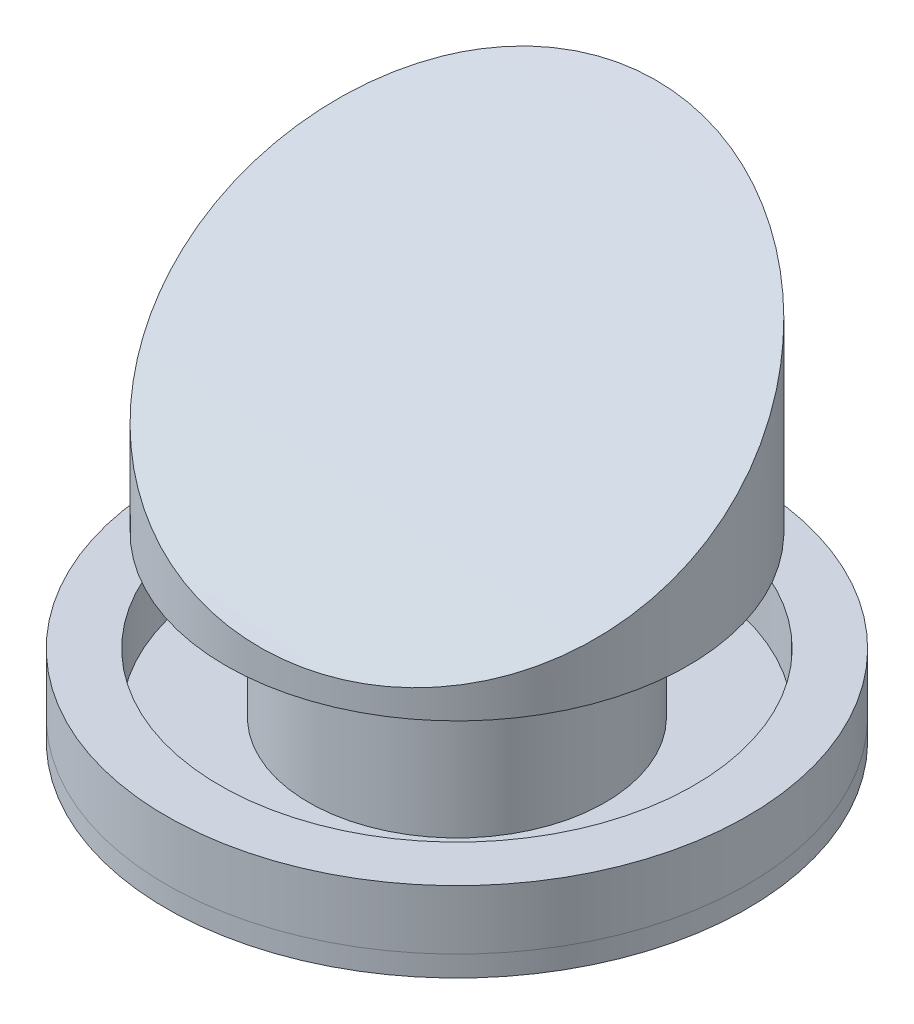
from build123d import *

# Parameters (mm, degrees)
ESBO_O4_R                            = 12
CORTE_EXTRUS_O1_DEPTH                = 776
ESBO_O3_W                            = 90
ESBO_O3_H                            = 100
FURO_ROSCADO_DE_M20X1_01_AT_2_COUNT  = 2
FURO_ROSCADO_DE_M20X1_01_AT_2_PITCH  = 140.791018536
FURO_ROSCADO_DE_M20X1_01_AT_3_COUNT  = 2
FURO_ROSCADO_DE_M20X1_01_AT_3_PITCH  = 278.115294937
FURO_ROSCADO_DE_M20X1_01_AT_4_COUNT  = 2
FURO_ROSCADO_DE_M20X1_01_AT_4_PITCH  = 408.591449766
FURO_ROSCADO_DE_M20X1_01_AT_5_COUNT  = 2
FURO_ROSCADO_DE_M20X1_01_AT_5_PITCH  = 529.006727063
FURO_ROSCADO_DE_M20X1_01_AT_6_COUNT  = 2
FURO_ROSCADO_DE_M20X1_01_AT_6_PITCH  = 636.396103068
FURO_ROSCADO_DE_M20X1_01_AT_7_COUNT  = 2
FURO_ROSCADO_DE_M20X1_01_AT_7_PITCH  = 728.115294937
FURO_ROSCADO_DE_M20X1_01_AT_8_COUNT  = 2
FURO_ROSCADO_DE_M20X1_01_AT_8_PITCH  = 801.90587177
FURO_ROSCADO_DE_M20X1_01_AT_9_COUNT  = 2
FURO_ROSCADO_DE_M20X1_01_AT_9_PITCH  = 855.950864666
FURO_ROSCADO_DE_M20X1_01_AT_10_COUNT = 2
FURO_ROSCADO_DE_M20X1_01_AT_10_PITCH = 888.919506536
FURO_ROSCADO_DE_M20X1_01_AT_11_COUNT = 2
FURO_ROSCADO_DE_M20X1_01_AT_11_PITCH = 900
FURO_ROSCADO_DE_M20X1_01_AT_12_COUNT = 2
FURO_ROSCADO_DE_M20X1_01_AT_12_PITCH = 888.919506536
FURO_ROSCADO_DE_M20X1_01_AT_13_COUNT = 2
FURO_ROSCADO_DE_M20X1_01_AT_13_PITCH = 855.950864666
FURO_ROSCADO_DE_M20X1_01_AT_14_COUNT = 2
FURO_ROSCADO_DE_M20X1_01_AT_14_PITCH = 801.90587177
FURO_ROSCADO_DE_M20X1_01_AT_15_COUNT = 2
FURO_ROSCADO_DE_M20X1_01_AT_15_PITCH = 728.115294937
FURO_ROSCADO_DE_M20X1_01_AT_16_COUNT = 2
FURO_ROSCADO_DE_M20X1_01_AT_16_PITCH = 636.396103068
FURO_ROSCADO_DE_M20X1_01_AT_17_COUNT = 2
FURO_ROSCADO_DE_M20X1_01_AT_17_PITCH = 529.006727063
FURO_ROSCADO_DE_M20X1_01_AT_18_COUNT = 2
FURO_ROSCADO_DE_M20X1_01_AT_18_PITCH = 408.591449766
FURO_ROSCADO_DE_M20X1_01_AT_19_COUNT = 2
FURO_ROSCADO_DE_M20X1_01_AT_19_PITCH = 278.115294937
FURO_ROSCADO_DE_M20X1_01_AT_20_COUNT = 2
FURO_ROSCADO_DE_M20X1_01_AT_20_PITCH = 140.791018536


with BuildPart() as part:
    # Esboço2 → Revolução1 (revolve)
    with BuildSketch(Plane.XY):
        Polygon((0, 0), (490, 0), (490, 35), (250, 35), (250, 305), (390, 305), (390, 775), (0, 775), (0, 305), (230, 305), (230, 35), (0, 35), align=None)
    revolve(axis=Axis((0, 0, 0), (0, 1, 0)))

    # Esboço4 → Corte-extrusão1 (cut, through all)
    with BuildSketch(Plane(origin=(0, 0, 0), x_dir=(-1, 0, 0), z_dir=(0, -1, 0))):
        with Locations((0, -450)):
            Circle(ESBO_O4_R)
        with Locations((-139.057647469, -427.975432333)):
            Circle(ESBO_O4_R)
        with Locations((-264.503363532, -364.057647469)):
            Circle(ESBO_O4_R)
        with Locations((-364.057647469, -264.503363532)):
            Circle(ESBO_O4_R)
        with Locations((-427.975432333, -139.057647469)):
            Circle(ESBO_O4_R)
        with Locations((-450, 0)):
            Circle(ESBO_O4_R)
        with Locations((-427.975432333, 139.057647469)):
            Circle(ESBO_O4_R)
        with Locations((-364.057647469, 264.503363532)):
            Circle(ESBO_O4_R)
        with Locations((-264.503363532, 364.057647469)):
            Circle(ESBO_O4_R)
        with Locations((-139.057647469, 427.975432333)):
            Circle(ESBO_O4_R)
        with Locations((0, 450)):
            Circle(ESBO_O4_R)
        with Locations((139.057647469, 427.975432333)):
            Circle(ESBO_O4_R)
        with Locations((264.503363532, 364.057647469)):
            Circle(ESBO_O4_R)
        with Locations((364.057647469, 264.503363532)):
            Circle(ESBO_O4_R)
        with Locations((427.975432333, 139.057647469)):
            Circle(ESBO_O4_R)
        with Locations((450, 0)):
            Circle(ESBO_O4_R)
        with Locations((427.975432333, -139.057647469)):
            Circle(ESBO_O4_R)
        with Locations((364.057647469, -264.503363532)):
            Circle(ESBO_O4_R)
        with Locations((264.503363532, -364.057647469)):
            Circle(ESBO_O4_R)
        with Locations((139.057647469, -427.975432333)):
            Circle(ESBO_O4_R)
    extrude(amount=-CORTE_EXTRUS_O1_DEPTH, mode=Mode.SUBTRACT)

    # Esboço10 → Corte-Revolução1 (revolve, cut)
    with BuildSketch(Plane.XY.offset(2200)):
        Polygon((-5755, 9250), (1345, 10524), (1345, 5159), (-5755, 5159), align=None)
    revolve(axis=Axis((1345, 5159, 2200), (-1, 0, 0)), mode=Mode.SUBTRACT)


with BuildPart() as body_2:
    # Esboço3 → Revolução2 (revolve)
    with BuildSketch(Plane.XY):
        with Locations((445, 85)):
            Rectangle(ESBO_O3_W, ESBO_O3_H)
    revolve(axis=Axis((0, 0, 0), (0, 1, 0)))

    # Esboço5 → Furo roscado de M20x1.01 (revolve, cut)
    with BuildSketch(Plane(origin=(0, 35, 450), x_dir=(0, 0, -1), z_dir=(1, 0, 0))):
        Polygon((0, 0), (0, 50.878175881), (9.5, 45.17), (9.5, 0), align=None)
    furo_roscado_de_m20x1_01 = revolve(axis=Axis((0, 28.65, 450), (0, 1, 0)), mode=Mode.SUBTRACT)

    # Furo roscado de M20x1.01 at 2: Furo roscado de M20x1.01 ×2
    with Locations(*[Vector(0.987688341, 0, -0.156434465) * (i * FURO_ROSCADO_DE_M20X1_01_AT_2_PITCH) for i in range(1, FURO_ROSCADO_DE_M20X1_01_AT_2_COUNT)]):
        add(furo_roscado_de_m20x1_01, mode=Mode.SUBTRACT)

    # Furo roscado de M20x1.01 at 3: Furo roscado de M20x1.01 ×2
    with Locations(*[Vector(0.951056516, 0, -0.309016994) * (i * FURO_ROSCADO_DE_M20X1_01_AT_3_PITCH) for i in range(1, FURO_ROSCADO_DE_M20X1_01_AT_3_COUNT)]):
        add(furo_roscado_de_m20x1_01, mode=Mode.SUBTRACT)

    # Furo roscado de M20x1.01 at 4: Furo roscado de M20x1.01 ×2
    with Locations(*[Vector(0.891006524, 0, -0.4539905) * (i * FURO_ROSCADO_DE_M20X1_01_AT_4_PITCH) for i in range(1, FURO_ROSCADO_DE_M20X1_01_AT_4_COUNT)]):
        add(furo_roscado_de_m20x1_01, mode=Mode.SUBTRACT)

    # Furo roscado de M20x1.01 at 5: Furo roscado de M20x1.01 ×2
    with Locations(*[Vector(0.809016994, 0, -0.587785252) * (i * FURO_ROSCADO_DE_M20X1_01_AT_5_PITCH) for i in range(1, FURO_ROSCADO_DE_M20X1_01_AT_5_COUNT)]):
        add(furo_roscado_de_m20x1_01, mode=Mode.SUBTRACT)

    # Furo roscado de M20x1.01 at 6: Furo roscado de M20x1.01 ×2
    with Locations(*[Vector(0.707106781, 0, -0.707106781) * (i * FURO_ROSCADO_DE_M20X1_01_AT_6_PITCH) for i in range(1, FURO_ROSCADO_DE_M20X1_01_AT_6_COUNT)]):
        add(furo_roscado_de_m20x1_01, mode=Mode.SUBTRACT)

    # Furo roscado de M20x1.01 at 7: Furo roscado de M20x1.01 ×2
    with Locations(*[Vector(0.587785252, 0, -0.809016994) * (i * FURO_ROSCADO_DE_M20X1_01_AT_7_PITCH) for i in range(1, FURO_ROSCADO_DE_M20X1_01_AT_7_COUNT)]):
        add(furo_roscado_de_m20x1_01, mode=Mode.SUBTRACT)

    # Furo roscado de M20x1.01 at 8: Furo roscado de M20x1.01 ×2
    with Locations(*[Vector(0.4539905, 0, -0.891006524) * (i * FURO_ROSCADO_DE_M20X1_01_AT_8_PITCH) for i in range(1, FURO_ROSCADO_DE_M20X1_01_AT_8_COUNT)]):
        add(furo_roscado_de_m20x1_01, mode=Mode.SUBTRACT)

    # Furo roscado de M20x1.01 at 9: Furo roscado de M20x1.01 ×2
    with Locations(*[Vector(0.309016994, 0, -0.951056516) * (i * FURO_ROSCADO_DE_M20X1_01_AT_9_PITCH) for i in range(1, FURO_ROSCADO_DE_M20X1_01_AT_9_COUNT)]):
        add(furo_roscado_de_m20x1_01, mode=Mode.SUBTRACT)

    # Furo roscado de M20x1.01 at 10: Furo roscado de M20x1.01 ×2
    with Locations(*[Vector(0.156434465, 0, -0.987688341) * (i * FURO_ROSCADO_DE_M20X1_01_AT_10_PITCH) for i in range(1, FURO_ROSCADO_DE_M20X1_01_AT_10_COUNT)]):
        add(furo_roscado_de_m20x1_01, mode=Mode.SUBTRACT)

    # Furo roscado de M20x1.01 at 11: Furo roscado de M20x1.01 ×2
    with Locations(*[(0, 0, -i * FURO_ROSCADO_DE_M20X1_01_AT_11_PITCH) for i in range(1, FURO_ROSCADO_DE_M20X1_01_AT_11_COUNT)]):
        add(furo_roscado_de_m20x1_01, mode=Mode.SUBTRACT)

    # Furo roscado de M20x1.01 at 12: Furo roscado de M20x1.01 ×2
    with Locations(*[Vector(-0.156434465, 0, -0.987688341) * (i * FURO_ROSCADO_DE_M20X1_01_AT_12_PITCH) for i in range(1, FURO_ROSCADO_DE_M20X1_01_AT_12_COUNT)]):
        add(furo_roscado_de_m20x1_01, mode=Mode.SUBTRACT)

    # Furo roscado de M20x1.01 at 13: Furo roscado de M20x1.01 ×2
    with Locations(*[Vector(-0.309016994, 0, -0.951056516) * (i * FURO_ROSCADO_DE_M20X1_01_AT_13_PITCH) for i in range(1, FURO_ROSCADO_DE_M20X1_01_AT_13_COUNT)]):
        add(furo_roscado_de_m20x1_01, mode=Mode.SUBTRACT)

    # Furo roscado de M20x1.01 at 14: Furo roscado de M20x1.01 ×2
    with Locations(*[Vector(-0.4539905, 0, -0.891006524) * (i * FURO_ROSCADO_DE_M20X1_01_AT_14_PITCH) for i in range(1, FURO_ROSCADO_DE_M20X1_01_AT_14_COUNT)]):
        add(furo_roscado_de_m20x1_01, mode=Mode.SUBTRACT)

    # Furo roscado de M20x1.01 at 15: Furo roscado de M20x1.01 ×2
    with Locations(*[Vector(-0.587785252, 0, -0.809016994) * (i * FURO_ROSCADO_DE_M20X1_01_AT_15_PITCH) for i in range(1, FURO_ROSCADO_DE_M20X1_01_AT_15_COUNT)]):
        add(furo_roscado_de_m20x1_01, mode=Mode.SUBTRACT)

    # Furo roscado de M20x1.01 at 16: Furo roscado de M20x1.01 ×2
    with Locations(*[Vector(-0.707106781, 0, -0.707106781) * (i * FURO_ROSCADO_DE_M20X1_01_AT_16_PITCH) for i in range(1, FURO_ROSCADO_DE_M20X1_01_AT_16_COUNT)]):
        add(furo_roscado_de_m20x1_01, mode=Mode.SUBTRACT)

    # Furo roscado de M20x1.01 at 17: Furo roscado de M20x1.01 ×2
    with Locations(*[Vector(-0.809016994, 0, -0.587785252) * (i * FURO_ROSCADO_DE_M20X1_01_AT_17_PITCH) for i in range(1, FURO_ROSCADO_DE_M20X1_01_AT_17_COUNT)]):
        add(furo_roscado_de_m20x1_01, mode=Mode.SUBTRACT)

    # Furo roscado de M20x1.01 at 18: Furo roscado de M20x1.01 ×2
    with Locations(*[Vector(-0.891006524, 0, -0.4539905) * (i * FURO_ROSCADO_DE_M20X1_01_AT_18_PITCH) for i in range(1, FURO_ROSCADO_DE_M20X1_01_AT_18_COUNT)]):
        add(furo_roscado_de_m20x1_01, mode=Mode.SUBTRACT)

    # Furo roscado de M20x1.01 at 19: Furo roscado de M20x1.01 ×2
    with Locations(*[Vector(-0.951056516, 0, -0.309016994) * (i * FURO_ROSCADO_DE_M20X1_01_AT_19_PITCH) for i in range(1, FURO_ROSCADO_DE_M20X1_01_AT_19_COUNT)]):
        add(furo_roscado_de_m20x1_01, mode=Mode.SUBTRACT)

    # Furo roscado de M20x1.01 at 20: Furo roscado de M20x1.01 ×2
    with Locations(*[Vector(-0.987688341, 0, -0.156434465) * (i * FURO_ROSCADO_DE_M20X1_01_AT_20_PITCH) for i in range(1, FURO_ROSCADO_DE_M20X1_01_AT_20_COUNT)]):
        add(furo_roscado_de_m20x1_01, mode=Mode.SUBTRACT)


solid = Compound([part.part, body_2.part])
